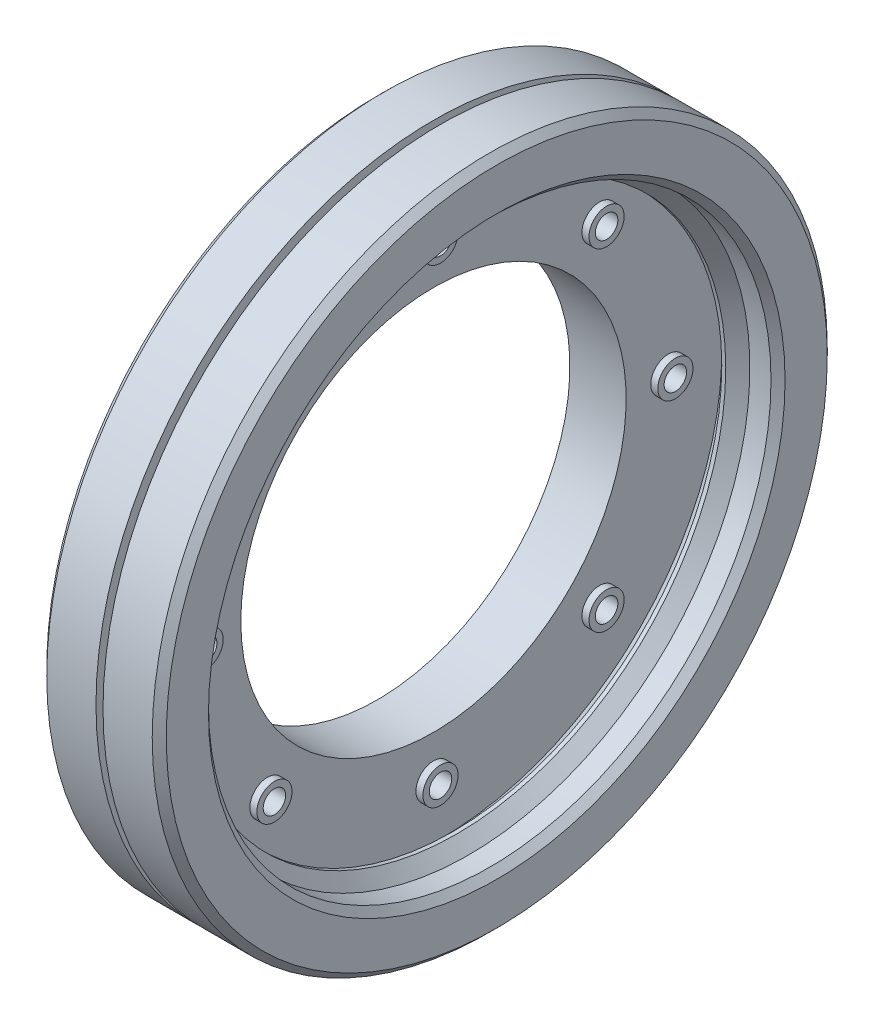
from build123d import *

# Parameters (mm, degrees)
SKETCH1_4_W         = 8
SKETCH1_4_H         = 20.6
SKETCH2_R           = 1.6
CUT_EXTRUDE1_DEPTH  = 10
SKETCH2_3_R         = 2.5
SKETCH2_3_R_2       = 1.6
BOSS_EXTRUDE1_DEPTH = 1
CIRPATTERN4_COUNT   = 8
CHAMFER4_SIZE       = 0.4
CHAMFER5_SIZE       = 1
CHAMFER6_SIZE       = 1


with BuildPart() as part:
    # Sketch1 → Revolve1 (revolve)
    with BuildSketch(Plane(origin=(0, 0, 0), x_dir=(1, 0, 0), z_dir=(0, 1, 0))):
        Polygon((2, 38), (4, 40), (8, 40), (8, 48), (0, 48), (0, 40), align=None)
    revolve(axis=Axis((0, 0, 0), (1, 0, 0)))

    # Chamfer4
    chamfer4_edges = [part.edges().sort_by_distance(p)[0] for p in [
        (2, 0, 38),
    ]]
    chamfer(chamfer4_edges, length=CHAMFER4_SIZE)

    # Chamfer5
    chamfer5_edges = [part.edges().sort_by_distance(p)[0] for p in [
        (8, 0, 48),
        (8, 0, 40),
    ]]
    chamfer(chamfer5_edges, length=CHAMFER5_SIZE)


with BuildPart() as body_2:
    # Sketch1_4 → Revolve2 (revolve)
    with BuildSketch(Plane(origin=(0, 0, 0), x_dir=(1, 0, 0), z_dir=(0, 1, 0))):
        with Locations((-5, 37.7)):
            Rectangle(SKETCH1_4_W, SKETCH1_4_H)
    revolve(axis=Axis((0, 0, 0), (1, 0, 0)))

    # Sketch2 → Cut-Extrude1 (cut)
    with BuildSketch(Plane(origin=(-1, 0, 0), x_dir=(0, 0, -1), z_dir=(1, 0, 0))):
        with Locations((33.4, 0)):
            Circle(SKETCH2_R)
    cut_extrude1 = extrude(amount=-CUT_EXTRUDE1_DEPTH, mode=Mode.SUBTRACT)

    # Sketch2_3 → Boss-Extrude1 (add)
    with BuildSketch(Plane(origin=(-1, 0, 0), x_dir=(0, 0, -1), z_dir=(1, 0, 0))):
        with Locations((33.4, 0)):
            Circle(SKETCH2_3_R)
        with Locations((33.4, 0)):
            Circle(SKETCH2_3_R_2, mode=Mode.SUBTRACT)
    boss_extrude1 = extrude(amount=BOSS_EXTRUDE1_DEPTH)

    # CirPattern4: Cut-Extrude1, Boss-Extrude1 ×8 about axis
    cirpattern4_axis = Axis((0, 0, 0), (-1, 0, 0))
    add([cut_extrude1.rotate(cirpattern4_axis, i * 360 / CIRPATTERN4_COUNT) for i in range(1, CIRPATTERN4_COUNT)], mode=Mode.SUBTRACT)
    add([boss_extrude1.rotate(cirpattern4_axis, i * 360 / CIRPATTERN4_COUNT) for i in range(1, CIRPATTERN4_COUNT)])

    # Chamfer6
    chamfer6_edges = [body_2.edges().sort_by_distance(p)[0] for p in [
        (-9, 0, 48),
    ]]
    chamfer(chamfer6_edges, length=CHAMFER6_SIZE)


solid = Compound([part.part, body_2.part])
